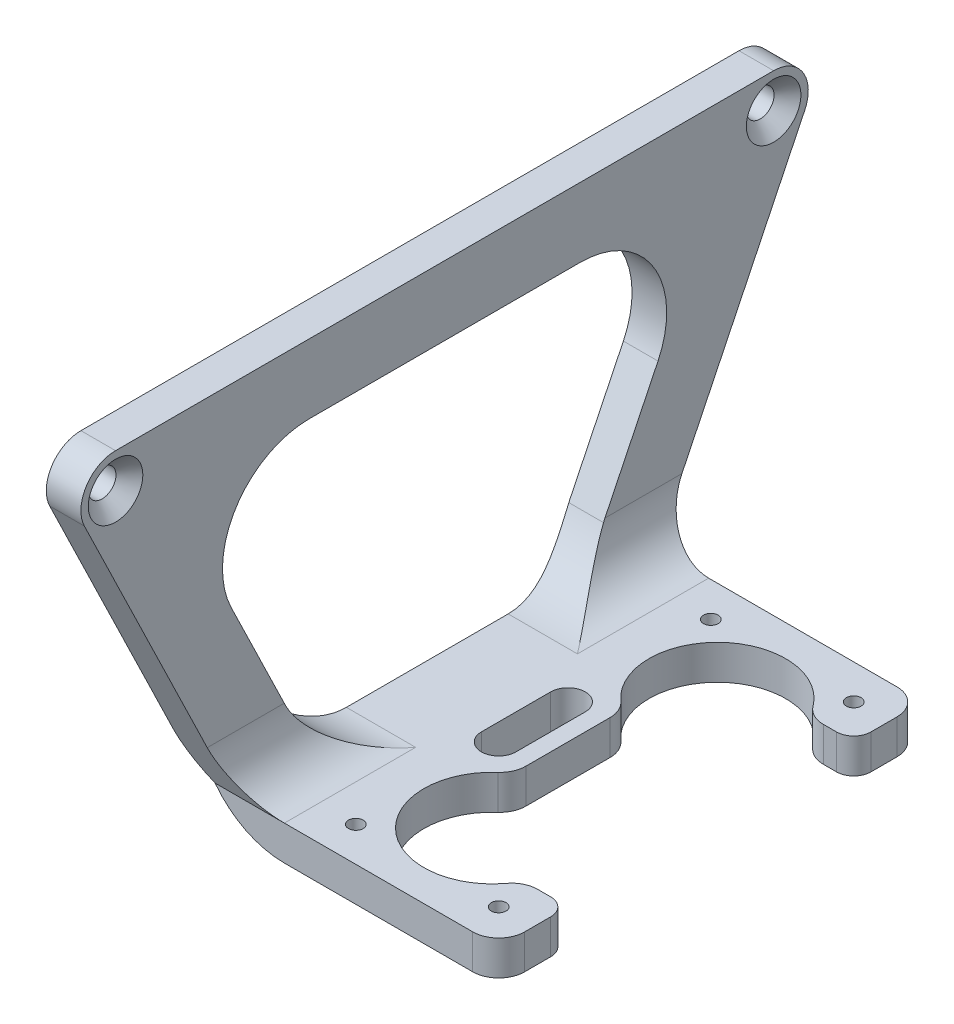
from build123d import *

# Parameters (mm, degrees)
BOSS_EXTRU_1_DEPTH                             = 84
FRAISAGE_POUR_VIS_T_TE_FRAIS_E_M31_D           = 3.2
FRAISAGE_POUR_VIS_T_TE_FRAIS_E_M31_DEPTH       = 4
FRAISAGE_POUR_VIS_T_TE_FRAIS_E_M31_CSINK_D     = 6.3
FRAISAGE_POUR_VIS_T_TE_FRAIS_E_M31_CSINK_ANGLE = 90
D_GAGEMENT_M1_61_D                             = 1.7
D_GAGEMENT_M1_61_DEPTH                         = 4
ENL_V_MAT_EXTRU_1_DEPTH                        = 4
ENL_V_MAT_EXTRU_2_DEPTH                        = 31.75
ENL_V_MAT_EXTRU_2_DEPTH_BACK                   = 5


with BuildPart() as part:
    # Esquisse1 → Boss.-Extru.1 (new body)
    with BuildSketch(Plane.XY):
        with BuildLine():
            Line((0, 0), (-25, 0))
            ThreePointArc((-25, 0), (-32.071067812, 2.928932188), (-35, 10))
            Line((-35, 10), (-35, 45))
            Line((-35, 45), (-31, 45))
            Line((-31, 45), (-31, 10))
            ThreePointArc((-31, 10), (-29.242640687, 5.757359313), (-25, 4))
            Line((-25, 4), (0, 4))
            Line((0, 4), (0, 0))
        make_face()
    extrude(amount=BOSS_EXTRU_1_DEPTH)

    # Fraisage pour vis à tête fraisée M31
    with Locations(Plane(origin=(-31, 0, 0), x_dir=(0, 0, 1), z_dir=(1, 0, 0))):
        with Locations((4, -41), (80, -41)):
            CounterSinkHole(FRAISAGE_POUR_VIS_T_TE_FRAIS_E_M31_D / 2, FRAISAGE_POUR_VIS_T_TE_FRAIS_E_M31_CSINK_D / 2, depth=FRAISAGE_POUR_VIS_T_TE_FRAIS_E_M31_DEPTH, counter_sink_angle=FRAISAGE_POUR_VIS_T_TE_FRAIS_E_M31_CSINK_ANGLE)

    # Dégagement M1.61
    with Locations(Plane(origin=(0, 0, 0), x_dir=(-1, 0, 0), z_dir=(0, -1, 0))):
        with Locations((20.75, -21.5), (20.75, -62.5), (4.25, -62.5), (4.25, -21.5)):
            Hole(D_GAGEMENT_M1_61_D / 2, depth=D_GAGEMENT_M1_61_DEPTH)

    # Esquisse6 → Enlèv. mat.-Extru.1 (cut)
    with BuildSketch(Plane.XZ):
        with BuildLine():
            Line((-35, 17.5), (-3.25, 17.5))
            ThreePointArc((-3.25, 17.5), (-1.128679656, 18.378679656), (-0.25, 20.5))
            Line((-0.25, 20.5), (-0.25, 23.5))
            ThreePointArc((-0.25, 23.5), (-0.835786438, 24.914213562), (-2.25, 25.5))
            Line((-2.25, 25.5), (-3.750142858, 25.5))
            ThreePointArc((-3.750142858, 25.5), (-5.097923909, 25.180202649), (-6.15836042, 24.288990826))
            ThreePointArc((-6.15836042, 24.288990826), (-17.832822404, 23.171534919), (-17.754587156, 34.899094322))
            ThreePointArc((-17.754587156, 34.899094322), (-17.012643745, 35.911706018), (-16.75, 37.139256723))
            Line((-16.75, 37.139256723), (-16.75, 46.860743277))
            ThreePointArc((-16.75, 46.860743277), (-17.012643745, 48.088293982), (-17.754587156, 49.100905678))
            ThreePointArc((-17.754587156, 49.100905678), (-17.832822404, 60.828465081), (-6.15836042, 59.711009174))
            ThreePointArc((-6.15836042, 59.711009174), (-5.097923909, 58.819797351), (-3.750142858, 58.5))
            Line((-3.750142858, 58.5), (-2.25, 58.5))
            ThreePointArc((-2.25, 58.5), (-0.835786438, 59.085786438), (-0.25, 60.5))
            Line((-0.25, 60.5), (-0.25, 63.5))
            ThreePointArc((-0.25, 63.5), (-1.128679656, 65.621320344), (-3.25, 66.5))
            Line((-3.25, 66.5), (-35, 66.5))
            Line((-35, 66.5), (-35, 84))
            Line((-35, 84), (0, 84))
            Line((0, 84), (0, 0))
            Line((0, 0), (-35, 0))
            Line((-35, 0), (-35, 17.5))
        make_face()
        with BuildLine():
            Line((-18.75, 46), (-18.75, 38))
            ThreePointArc((-18.75, 38), (-20.75, 36), (-22.75, 38))
            Line((-22.75, 38), (-22.75, 46))
            ThreePointArc((-22.75, 46), (-20.75, 48), (-18.75, 46))
        make_face()
    extrude(amount=-ENL_V_MAT_EXTRU_1_DEPTH, mode=Mode.SUBTRACT)

    # Esquisse7 → Enlèv. mat.-Extru.2 (cut, two sides)
    with BuildSketch(Plane(origin=(-31, 0, 0), x_dir=(0, 0, -1), z_dir=(1, 0, 0))) as enl_v_mat_extru_2_sk:
        with BuildLine():
            Line((-60.518790495, 10), (-23.481209505, 10))
            Line((-23.481209505, 10), (-17.352509418, 22.636031611))
            ThreePointArc((-17.352509418, 22.636031611), (-17.875393601, 32.308498663), (-26.350052411, 37))
            Line((-26.350052411, 37), (-57.649947589, 37))
            ThreePointArc((-57.649947589, 37), (-66.124606399, 32.308498663), (-66.647490582, 22.636031611))
            Line((-66.647490582, 22.636031611), (-60.518790495, 10))
        make_face()
        with BuildLine():
            Line((-23.657740647, 9.636031611), (-23.481209505, 10))
            Line((-23.481209505, 10), (-60.518790495, 10))
            Line((-60.518790495, 10), (-60.342259353, 9.636031611))
            ThreePointArc((-60.342259353, 9.636031611), (-56.653215023, 5.52534119), (-51.34471636, 4))
            Line((-51.34471636, 4), (-32.65528364, 4))
            ThreePointArc((-32.65528364, 4), (-27.346784977, 5.52534119), (-23.657740647, 9.636031611))
        make_face()
        Polygon((0, 4), (0, 10), (-14.589893279, 10), (-17.5, 4), align=None)
        with BuildLine():
            Line((0, 10), (0, 41))
            ThreePointArc((0, 41), (-0.101534354, 40.104474676), (-0.400982803, 39.254412644))
            Line((-0.400982803, 39.254412644), (-14.589893279, 10))
            Line((-14.589893279, 10), (0, 10))
        make_face()
        with BuildLine():
            ThreePointArc((-4, 45), (-1.171572875, 43.828427125), (0, 41))
            Line((0, 41), (0, 45))
            Line((0, 45), (-4, 45))
        make_face()
        with BuildLine():
            ThreePointArc((-83.599017197, 39.254412644), (-83.898465646, 40.104474676), (-84, 41))
            Line((-84, 41), (-84, 10))
            Line((-84, 10), (-69.410106721, 10))
            Line((-69.410106721, 10), (-83.599017197, 39.254412644))
        make_face()
        Polygon((-69.410106721, 10), (-84, 10), (-84, 4), (-66.5, 4), align=None)
        with BuildLine():
            ThreePointArc((-84, 41), (-82.828427125, 43.828427125), (-80, 45))
            Line((-80, 45), (-84, 45))
            Line((-84, 45), (-84, 41))
        make_face()
    extrude(amount=ENL_V_MAT_EXTRU_2_DEPTH, mode=Mode.SUBTRACT)
    extrude(enl_v_mat_extru_2_sk.sketch, amount=-ENL_V_MAT_EXTRU_2_DEPTH_BACK, mode=Mode.SUBTRACT)


solid = part.part
